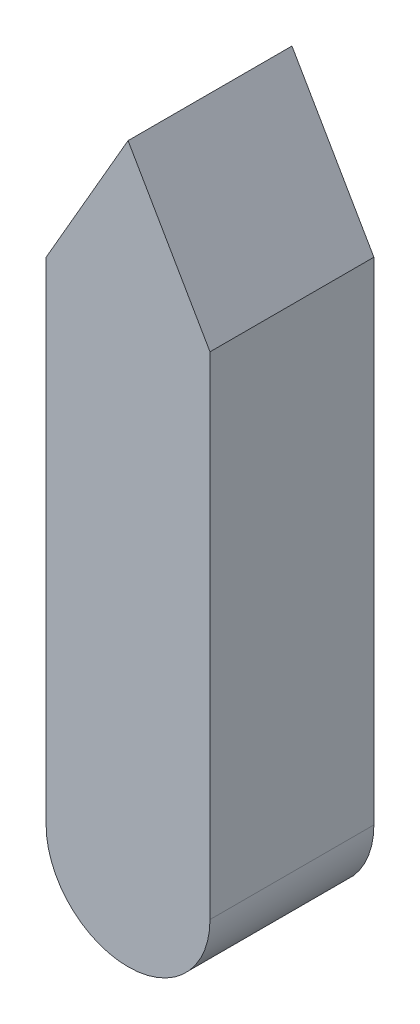
from build123d import *

# Parameters (mm, degrees)
CROQUIS2_W              = 100
CROQUIS2_H              = 300
SALIENTE_EXTRUIR2_DEPTH = 50


with BuildPart() as part:
    # Croquis2 → Saliente-Extruir2 (new body, symmetric)
    with BuildSketch(Plane.XY):
        Polygon((0, 236.602540378), (50, 150), (-50, 150), align=None)
        Rectangle(CROQUIS2_W, CROQUIS2_H)
        with BuildLine():
            Line((50, -150), (-50, -150))
            ThreePointArc((-50, -150), (0, -200), (50, -150))
        make_face()
    extrude(amount=SALIENTE_EXTRUIR2_DEPTH, both=True)


solid = part.part
